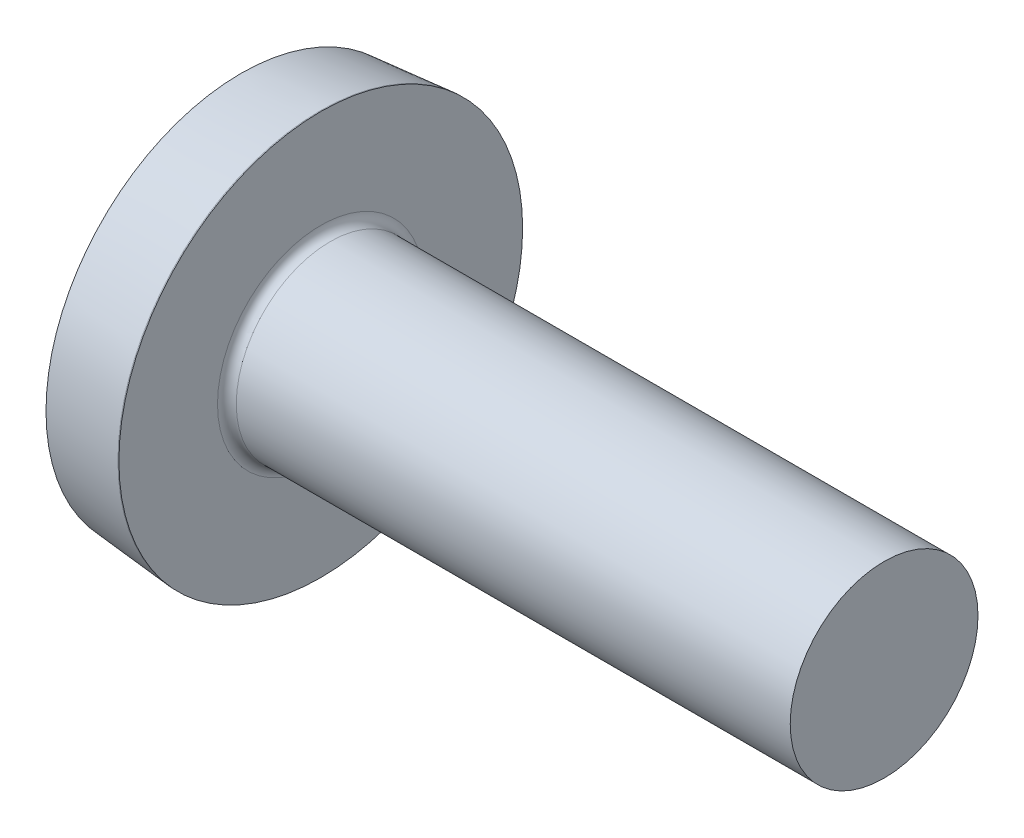
from build123d import *

# Parameters (mm, degrees)
FILLET1_R    = 0.1
SKETCH3_W    = 0.74
SKETCH3_H    = 2.2
SKETCH4_W    = 0.74
SKETCH4_H    = 1.19286532
RECPAT_COUNT = 2
RECPAT_ANGLE = 90


with BuildPart() as part:
    # BodySke → Base-Revolve (revolve)
    with BuildSketch(Plane.XY, mode=Mode.PRIVATE) as base_revolve_sk:
        with BuildLine():
            Line((1.2, 1), (1.2, 2.15))
            Line((1.2, 2.15), (1.19, 2.15))
            Line((1.19, 2.15), (0.35, 2.076509523))
            ThreePointArc((0.35, 2.076509523), (0.08811279, 1.052899781), (0, 0))
            Line((0, 0), (7.2, 0))
            Line((7.2, 0), (7.2, 1))
            Line((7.2, 1), (1.2, 1))
        make_face()
    revolve(base_revolve_sk.sketch.rotate(Axis((-25.4, 0, 0), (1, 0, 0)), 90), axis=Axis((-25.4, 0, 0), (1, 0, 0)))  # turned: the seam where the file's is

    # Fillet1
    fillet1_edges = [part.edges().sort_by_distance(p)[0] for p in [
        (1.2, 0, -1),
    ]]
    fillet(fillet1_edges, radius=FILLET1_R)

    # Sketch3 → Recess section 0
    with BuildSketch(Plane(origin=(0, 0, 0), x_dir=(0, 0, -1), z_dir=(1, 0, 0))):
        Rectangle(SKETCH3_W, SKETCH3_H)
    # Sketch4 → Recess section 1
    with BuildSketch(Plane(origin=(1.01, 0, 0), x_dir=(0, 0, -1), z_dir=(1, 0, 0))):
        Rectangle(SKETCH4_W, SKETCH4_H)
    recess = loft(mode=Mode.SUBTRACT)

    # RecPat: Recess ×2 about axis
    recpat_axis = Axis((0, 0, 0), (1, 0, 0))
    for i in range(1, RECPAT_COUNT):
        add(recess.rotate(recpat_axis, i * RECPAT_ANGLE / (RECPAT_COUNT - 1)), mode=Mode.SUBTRACT)

    # RecCorSke → RecessCore (revolve, cut)
    with BuildSketch(Plane.XY, mode=Mode.PRIVATE) as recesscore_sk:
        Polygon((0, 0), (0, 0.62662608), (1.01, 0.556), (1.190655351, 0), align=None)
    revolve(recesscore_sk.sketch.rotate(Axis((-3.175, 0, 0), (1, 0, 0)), 90), axis=Axis((-3.175, 0, 0), (1, 0, 0)), mode=Mode.SUBTRACT)  # turned: the seam where the file's is


solid = part.part
